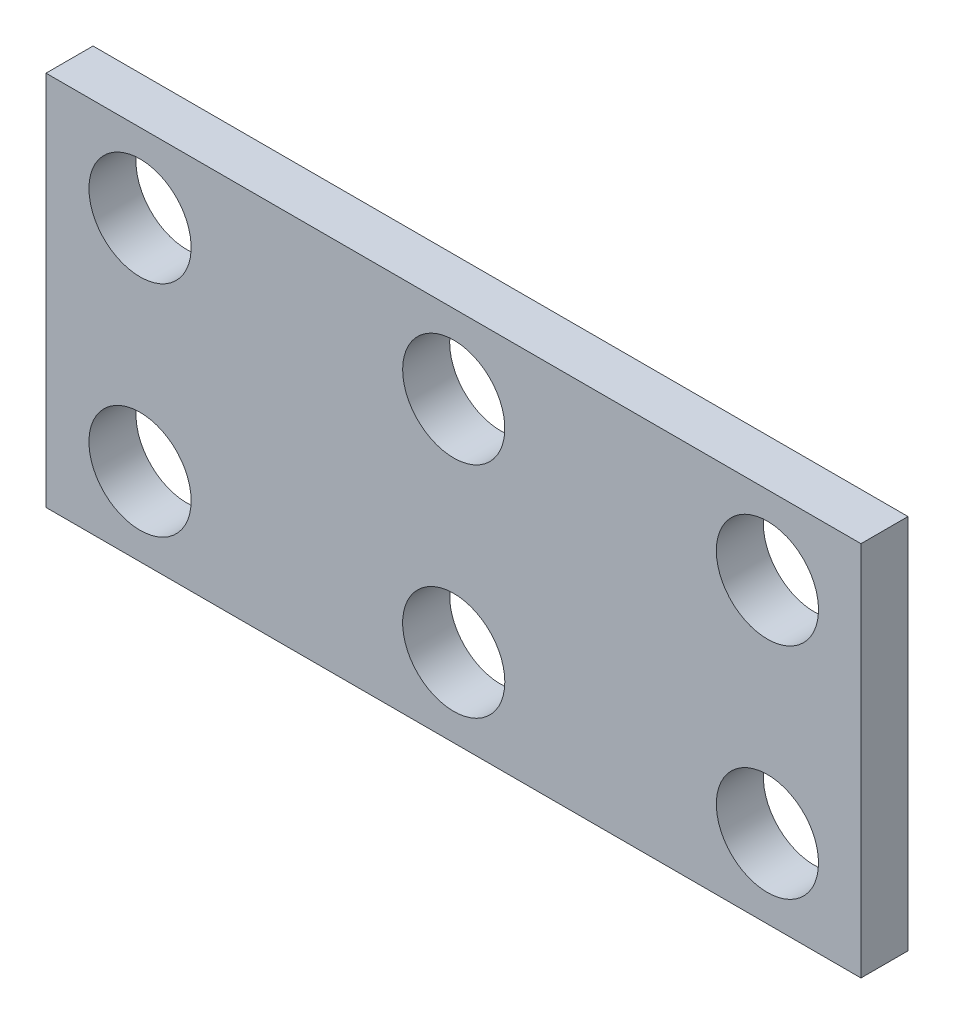
from build123d import *

# Parameters (mm, degrees)
SKETCH1_W      = 26
SKETCH1_H      = 12
EXTRUDE1_DEPTH = 1.5
SKETCH2_R      = 1.63
EXTRUDE2_DEPTH = 2.5


with BuildPart() as part:
    # Sketch1 → Extrude1 (new body)
    with BuildSketch(Plane.XY):
        with Locations((-13, 6)):
            Rectangle(SKETCH1_W, SKETCH1_H)
    extrude(amount=-EXTRUDE1_DEPTH)

    # Sketch2 → Extrude2 (cut, through all)
    with BuildSketch(Plane.XY):
        with Locations((-12.9924, 2.5)):
            Circle(SKETCH2_R)
        with Locations((-2.9848, 2.5)):
            Circle(SKETCH2_R)
        with Locations(Location((-2.9848, 9.5, 0), (0, 0, 180))):  # turned: the seam where the file's is
            Circle(SKETCH2_R)
        with Locations(Location((-12.9924, 9.5, 0), (0, 0, 180))):  # turned: the seam where the file's is
            Circle(SKETCH2_R)
        with Locations((-23, 2.5)):
            Circle(SKETCH2_R)
        with Locations(Location((-23, 9.5, 0), (0, 0, 180))):  # turned: the seam where the file's is
            Circle(SKETCH2_R)
    extrude(amount=-EXTRUDE2_DEPTH, mode=Mode.SUBTRACT)


solid = part.part
